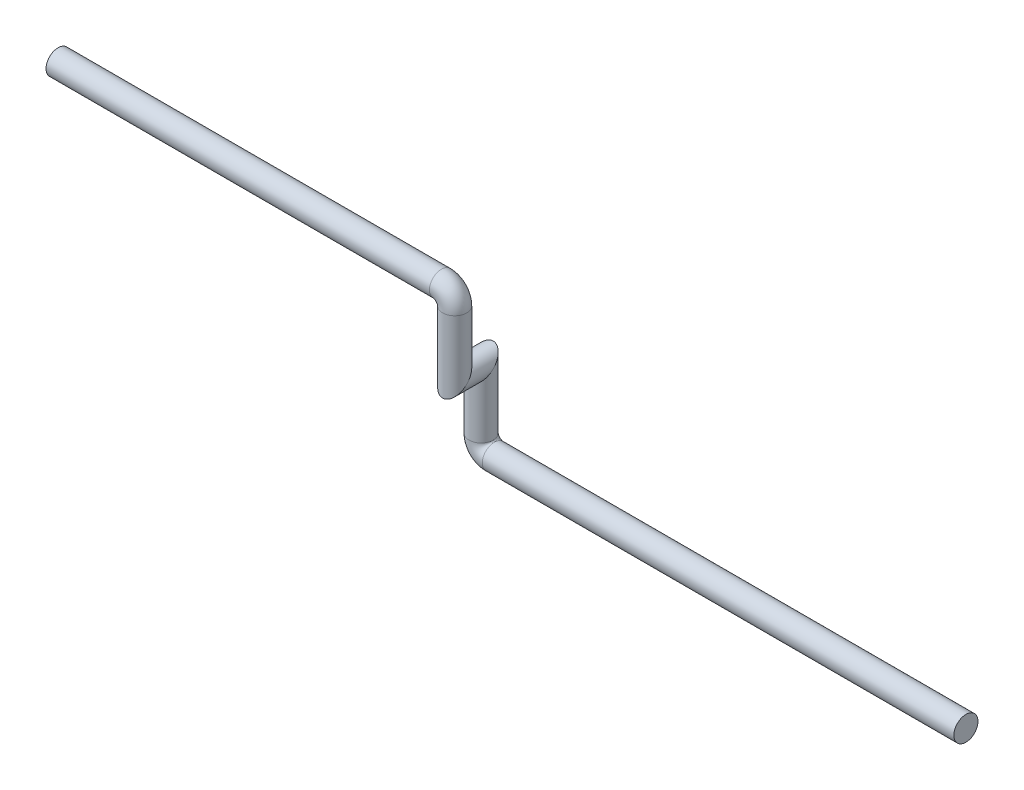
from build123d import *

# Parameters (mm, degrees)
CROQUIS1_R = 13.7


with BuildPart() as part:
    # Barrer1: sweep along a curve in space
    with BuildLine() as barrer1_path:
        Line((0, 0, 0), (-535, 0, 0))
        ThreePointArc((-535, 0, 0), (-545.606601718, 4.393398282, 0), (-550, 15, 0))
        Line((-550, 15, 0), (-550, 85, 0))
        Line((-550, 85, 0), (-550, 85, 30))
        Line((-550, 85, 30), (-550, 155, 30))
        ThreePointArc((-550, 155, 30), (-554.393398282, 165.606601718, 30), (-565, 170, 30))
        Line((-565, 170, 30), (-1000, 170, 30))
    # Croquis1 → Barrer1 (sweep)
    with BuildSketch(Plane(origin=(0, 0, 0), x_dir=(0, 0, -1), z_dir=(1, 0, 0))):
        Circle(CROQUIS1_R)
    sweep(path=barrer1_path.line, transition=Transition.RIGHT)


solid = part.part
